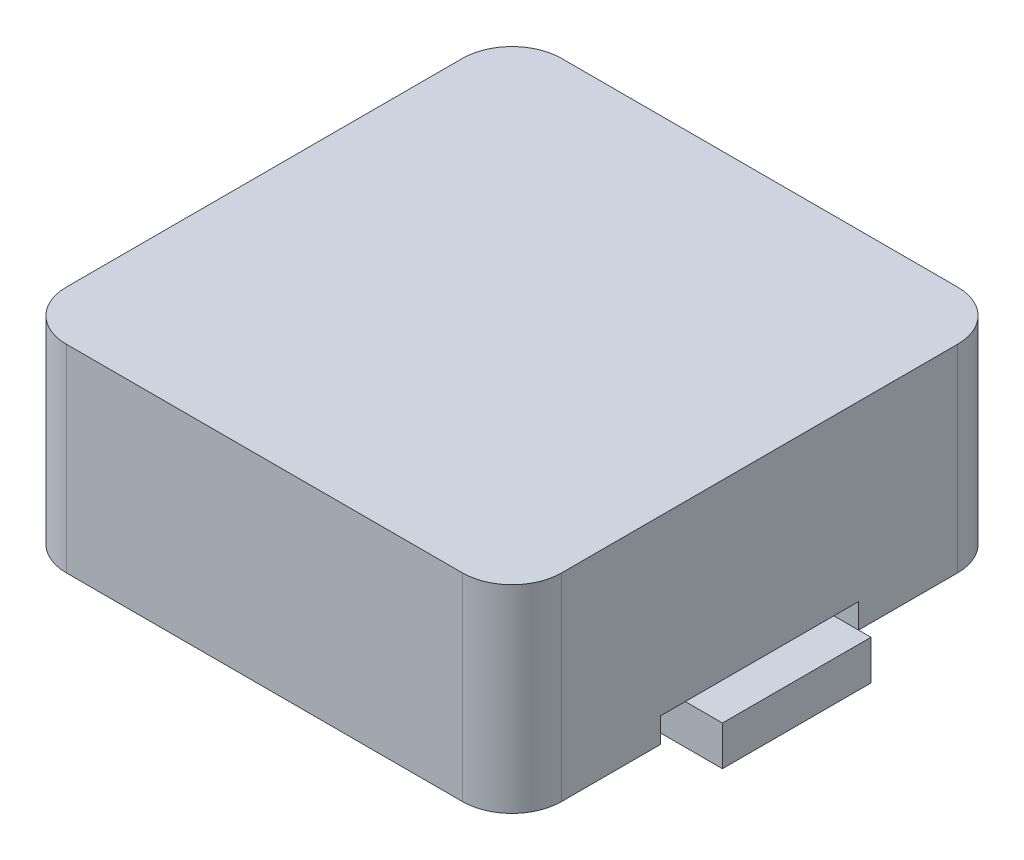
from build123d import *

# Parameters (mm, degrees)
BOSS_EXTRUDE1_DEPTH = 4
SKETCH2_W           = 2
SKETCH2_H           = 4
CUT_EXTRUDE1_DEPTH  = 0.5
SKETCH3_W           = 1.75
SKETCH3_H           = 3
SKETCH3_W_2         = 1.75632414
BOSS_EXTRUDE2_DEPTH = 0.8


with BuildPart() as part:
    # Sketch1 → Boss-Extrude1 (new body)
    with BuildSketch(Plane(origin=(0, 0, 0), x_dir=(1, 0, 0), z_dir=(0, 1, 0))):
        with BuildLine():
            Line((-4, -5), (4, -5))
            ThreePointArc((4, -5), (4.707106781, -4.707106781), (5, -4))
            Line((5, -4), (5, 4))
            ThreePointArc((5, 4), (4.707106781, 4.707106781), (4, 5))
            Line((4, 5), (-4, 5))
            ThreePointArc((-4, 5), (-4.707106781, 4.707106781), (-5, 4))
            Line((-5, 4), (-5, -4))
            ThreePointArc((-5, -4), (-4.707106781, -4.707106781), (-4, -5))
        make_face()
    extrude(amount=BOSS_EXTRUDE1_DEPTH)

    # Sketch2 → Cut-Extrude1 (cut)
    with BuildSketch(Plane(origin=(0, 0, 0), x_dir=(1, 0, 0), z_dir=(0, 1, 0))):
        with Locations((-5, 0)):
            Rectangle(SKETCH2_W, SKETCH2_H)
        with Locations((5, 0)):
            Rectangle(SKETCH2_W, SKETCH2_H)
    extrude(amount=CUT_EXTRUDE1_DEPTH, mode=Mode.SUBTRACT)

    # Sketch3 → Boss-Extrude2 (add)
    with BuildSketch(Plane.XZ.offset(-0.5)):
        with Locations((-4.875, 0)):
            Rectangle(SKETCH3_W, SKETCH3_H)
        with Locations((4.87183793, 0)):
            Rectangle(SKETCH3_W_2, SKETCH3_H)
    extrude(amount=BOSS_EXTRUDE2_DEPTH)


solid = part.part
